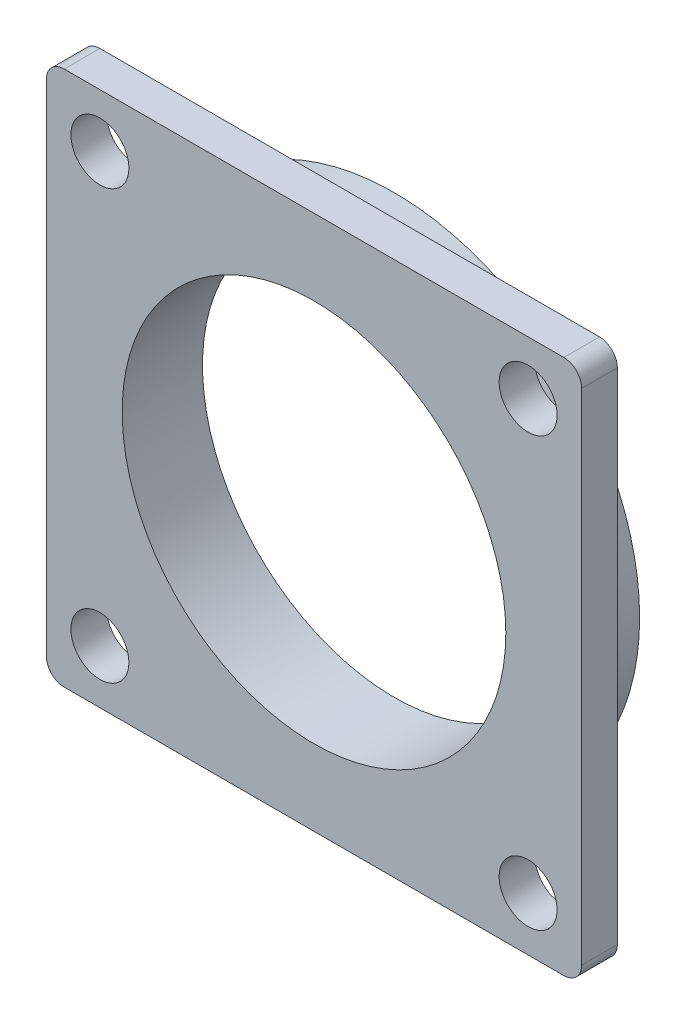
from build123d import *

# Parameters (mm, degrees)
ESQUISSE1_R             = 13.75
ESQUISSE1_R_2           = 10.75
BOSS_EXTRU_1_DEPTH      = 2.5
ESQUISSE2_W             = 30
ESQUISSE2_H             = 30
ESQUISSE2_R             = 1.625
BOSS_EXTRU_2_DEPTH      = 2
ESQUISSE3_R             = 10.75
ENL_V_MAT_EXTRU_1_DEPTH = 23
CONG_1_R                = 1


with BuildPart() as part:
    # Esquisse1 → Boss.-Extru.1 (new body)
    with BuildSketch(Plane.XY):
        with Locations((24.994563159, -11.631436553)):
            Circle(ESQUISSE1_R)
        with Locations((24.994563159, -11.631436553)):
            Circle(ESQUISSE1_R_2, mode=Mode.SUBTRACT)
    extrude(amount=BOSS_EXTRU_1_DEPTH)

    # Esquisse2 → Boss.-Extru.2 (add)
    with BuildSketch(Plane.XY.offset(2.5)):
        with Locations((24.994563159, -11.631436553)):
            Rectangle(ESQUISSE2_W, ESQUISSE2_H)
        with Locations((12.994563159, 0.368563447)):
            Circle(ESQUISSE2_R, mode=Mode.SUBTRACT)
        with Locations((36.994563159, 0.368563447)):
            Circle(ESQUISSE2_R, mode=Mode.SUBTRACT)
        with Locations((12.994563159, -23.631436553)):
            Circle(ESQUISSE2_R, mode=Mode.SUBTRACT)
        with Locations((36.994563159, -23.631436553)):
            Circle(ESQUISSE2_R, mode=Mode.SUBTRACT)
    extrude(amount=BOSS_EXTRU_2_DEPTH)

    # Esquisse3 → Enlèv. mat.-Extru.1 (cut)
    with BuildSketch(Plane(origin=(0, 0, 0), x_dir=(-1, 0, 0), z_dir=(0, 0, -1))):
        with Locations((-24.994563159, -11.631436553)):
            Circle(ESQUISSE3_R)
    extrude(amount=-ENL_V_MAT_EXTRU_1_DEPTH, mode=Mode.SUBTRACT)

    # Congé1
    cong_1_edges = [part.edges().sort_by_distance(p)[0] for p in [
        (9.994563159, 3.368563447, 3.5),
        (9.994563159, -26.631436553, 3.5),
        (39.994563159, -26.631436553, 3.5),
        (39.994563159, 3.368563447, 3.5),
    ]]
    fillet(cong_1_edges, radius=CONG_1_R)


solid = part.part
